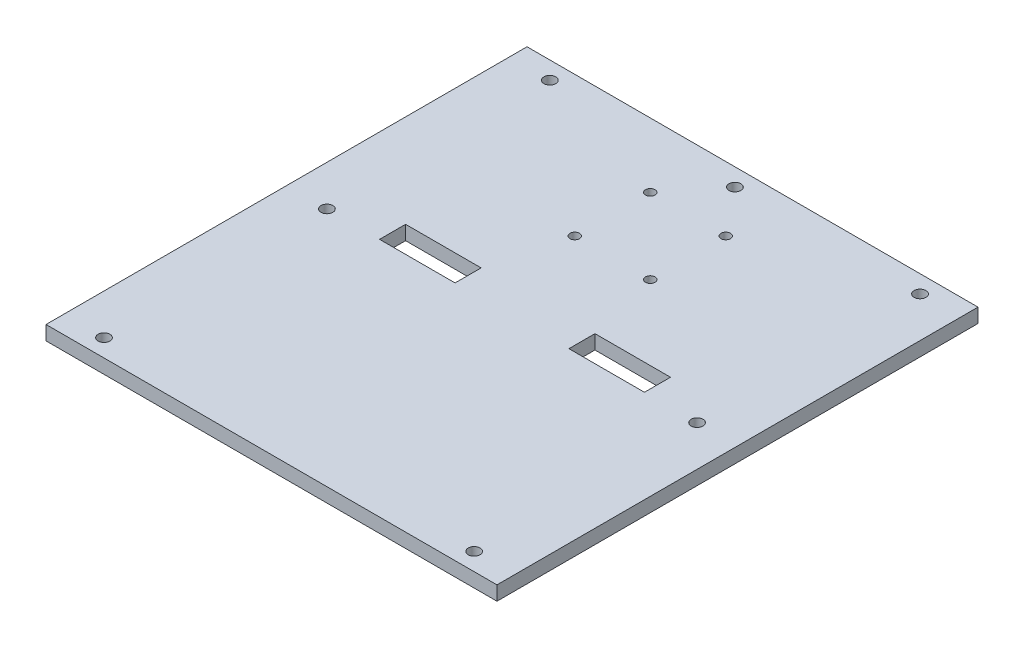
from build123d import *

# Parameters (mm, degrees)
SKETCH2_W           = 190.5
SKETCH2_H           = 203.2
BOSS_EXTRUDE1_DEPTH = 6
SKETCH5_R           = 2.5
CUT_EXTRUDE6_DEPTH  = 7
CUT_EXTRUDE7_DEPTH  = 10


with BuildPart() as part:
    # Sketch2 → Boss-Extrude1 (new body)
    with BuildSketch(Plane(origin=(0, 0, 0), x_dir=(1, 0, 0), z_dir=(0, 1, 0))):
        Rectangle(SKETCH2_W, SKETCH2_H)
    extrude(amount=BOSS_EXTRUDE1_DEPTH)

    # Sketch5 → Cut-Extrude6 (cut, through all)
    with BuildSketch(Plane(origin=(0, 6, 0), x_dir=(1, 0, 0), z_dir=(0, 1, 0))):
        with Locations((-78.187036158, 94.165073798)):
            Circle(SKETCH5_R)
        with Locations((0, 94.165073798)):
            Circle(SKETCH5_R)
        with Locations((78.187036158, 0)):
            Circle(SKETCH5_R)
        with Locations((-78.187036158, 0)):
            Circle(SKETCH5_R)
        with Locations((78.187036158, 94.165073798)):
            Circle(SKETCH5_R)
        with Locations((-78.187036158, -94.165073798)):
            Circle(SKETCH5_R)
        with Locations((78.187036158, -94.165073798)):
            Circle(SKETCH5_R)
    extrude(amount=-CUT_EXTRUDE6_DEPTH, mode=Mode.SUBTRACT)

    # Sketch6 → Cut-Extrude7 (cut)
    with BuildSketch(Plane(origin=(0, 6, 0), x_dir=(1, 0, 0), z_dir=(0, 1, 0))):
        with BuildLine():
            ThreePointArc((-13.95, 74.35), (-17.364213562, 75.764213562), (-15.95, 72.35))
            Line((-15.95, 72.35), (-15.95, 74.35))
            Line((-15.95, 74.35), (-13.95, 74.35))
        make_face()
        with BuildLine():
            Line((-15.95, 74.35), (-15.95, 72.35))
            ThreePointArc((-15.95, 72.35), (-14.535786438, 72.935786438), (-13.95, 74.35))
            Line((-13.95, 74.35), (-15.95, 74.35))
        make_face()
        with BuildLine():
            ThreePointArc((13.95, 74.35), (14.535786438, 72.935786438), (15.95, 72.35))
            Line((15.95, 72.35), (15.95, 74.35))
            Line((15.95, 74.35), (13.95, 74.35))
        make_face()
        with BuildLine():
            Line((15.95, 74.35), (15.95, 72.35))
            ThreePointArc((15.95, 72.35), (17.364213562, 72.935786438), (17.95, 74.35))
            ThreePointArc((17.95, 74.35), (15.95, 76.35), (13.95, 74.35))
            Line((13.95, 74.35), (15.95, 74.35))
        make_face()
        with BuildLine():
            Line((-15.95, 44.45), (-15.95, 42.45))
            Line((-15.95, 42.45), (-13.95, 42.45))
            ThreePointArc((-13.95, 42.45), (-14.535786438, 43.864213562), (-15.95, 44.45))
        make_face()
        with BuildLine():
            ThreePointArc((-15.95, 44.45), (-17.95, 42.45), (-15.95, 40.45))
            Line((-15.95, 40.45), (-15.95, 42.45))
            Line((-15.95, 42.45), (-15.95, 44.45))
        make_face()
        with BuildLine():
            ThreePointArc((15.95, 44.45), (14.535786438, 43.864213562), (13.95, 42.45))
            Line((13.95, 42.45), (15.95, 42.45))
            Line((15.95, 42.45), (15.95, 44.45))
        make_face()
        with BuildLine():
            Line((15.95, 42.45), (17.95, 42.45))
            ThreePointArc((17.95, 42.45), (17.364213562, 43.864213562), (15.95, 44.45))
            Line((15.95, 44.45), (15.95, 42.45))
        make_face()
        with BuildLine():
            ThreePointArc((13.95, 42.45), (15.95, 40.45), (17.95, 42.45))
            Line((17.95, 42.45), (15.95, 42.45))
            Line((15.95, 42.45), (13.95, 42.45))
        make_face()
        with BuildLine():
            Line((-15.95, 42.45), (-15.95, 40.45))
            ThreePointArc((-15.95, 40.45), (-14.535786438, 41.035786438), (-13.95, 42.45))
            Line((-13.95, 42.45), (-15.95, 42.45))
        make_face()
        Polygon((-55.95, 11), (-55.95, 0), (-24.05, 0), (-24.05, 11), (-40, 11), align=None)
        Polygon((40, 0), (55.95, 0), (55.95, 11), (40, 11), (24.05, 11), (24.05, 0), align=None)
    extrude(amount=-CUT_EXTRUDE7_DEPTH, mode=Mode.SUBTRACT)


solid = part.part
